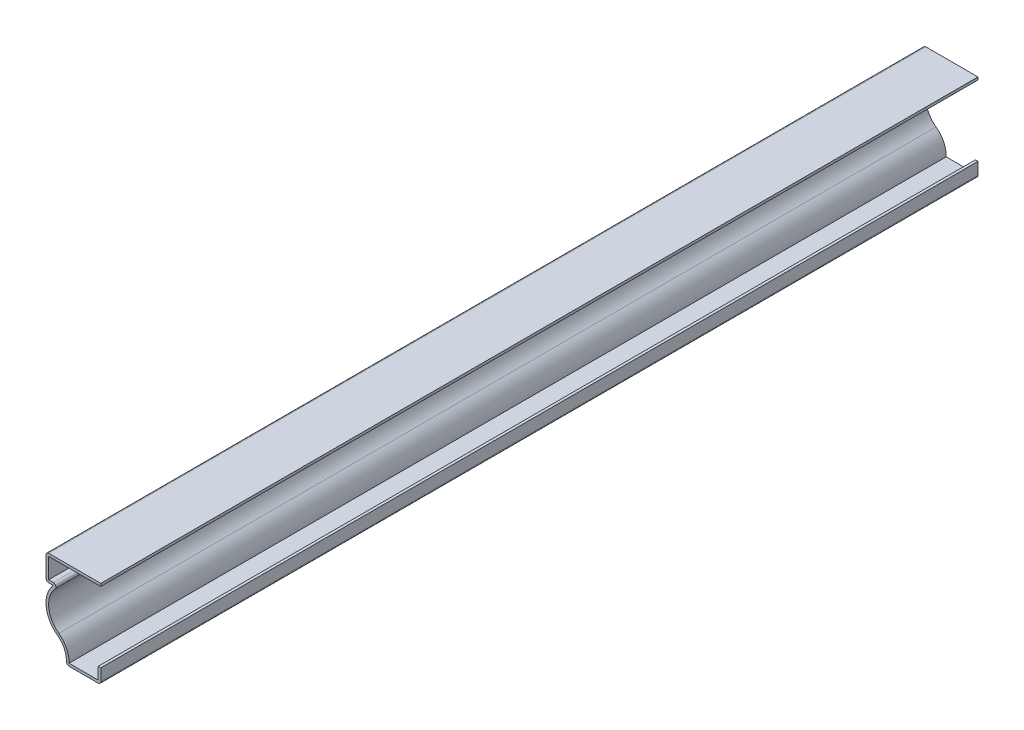
from build123d import *

# Parameters (mm, degrees)
EXTRUDE_THIN1_DEPTH = 381
FILLET1_R           = 1.143


with BuildPart() as part:
    # Sketch1 → Extrude-Thin1 (new body)
    with BuildSketch(Plane.XY):
        with BuildLine():
            Line((0, 6.35), (0, 0))
            Line((0, 0), (-15.08125, 0))
            ThreePointArc((-15.08125, 0), (-15.674145833, 5.166503616), (-18.892315645, 9.251557855))
            ThreePointArc((-18.892315645, 9.251557855), (-23.755275855, 17.726883992), (-20.6375, 26.9875))
            Line((-20.6375, 26.9875), (-23.8125, 26.9875))
            Line((-23.8125, 26.9875), (-23.8125, 38.1))
            Line((-23.8125, 38.1), (0, 38.1))
            Line((0, 38.1), (0, 36.957))
            Line((0, 36.957), (-22.6695, 36.957))
            Line((-22.6695, 36.957), (-22.6695, 28.1305))
            Line((-22.6695, 28.1305), (-17.430068405, 28.1305))
            ThreePointArc((-17.430068405, 28.1305), (-22.6590532, 19.366909782), (-18.221653343, 10.177117727))
            ThreePointArc((-18.221653343, 10.177117727), (-14.890707606, 6.21074153), (-13.820504151, 1.143))
            Line((-13.820504151, 1.143), (-1.143, 1.143))
            Line((-1.143, 1.143), (-1.143, 6.35))
            Line((-1.143, 6.35), (0, 6.35))
        make_face()
    extrude(amount=-EXTRUDE_THIN1_DEPTH)

    # Fillet1
    fillet1_edges = [part.edges().sort_by_distance(p)[0] for p in [
        (-17.430068405, 28.1305, -190.5),
        (0, 0, -190.5),
        (-15.08125, 0, -190.5),
        (-23.8125, 26.9875, -190.5),
        (-23.8125, 38.1, -190.5),
    ]]
    fillet(fillet1_edges, radius=FILLET1_R)


solid = part.part
